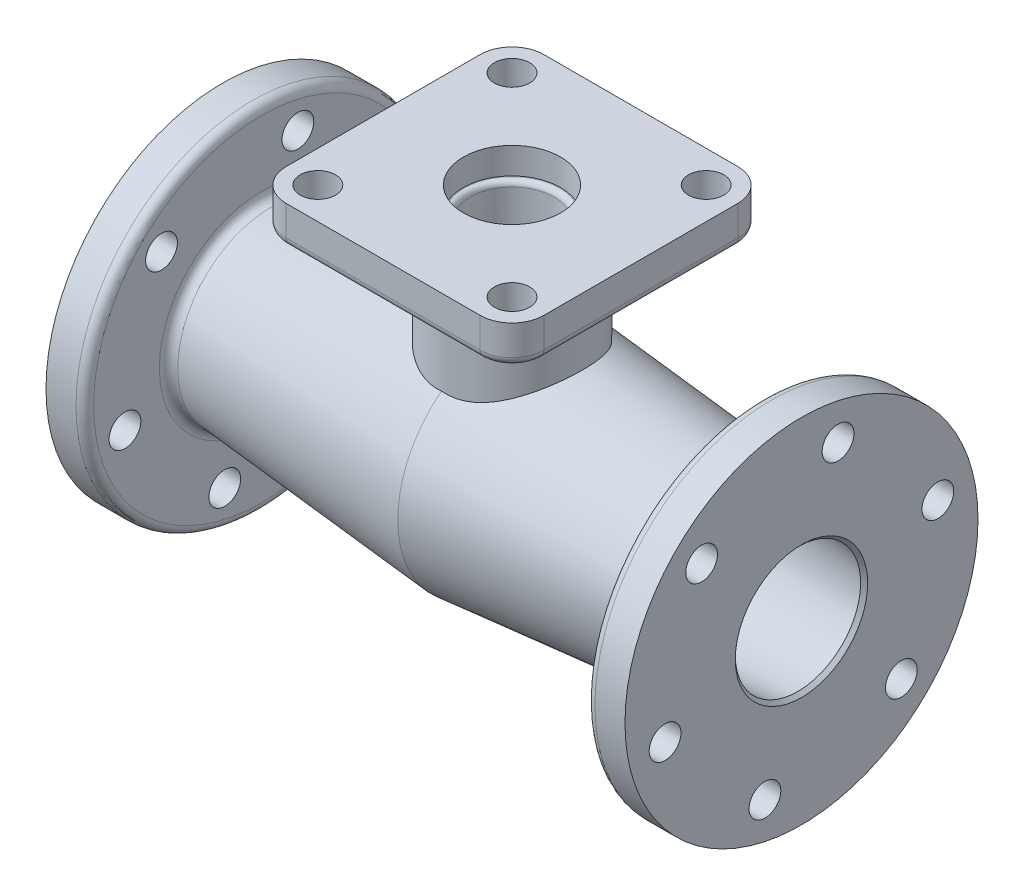
from build123d import *

# Parameters (mm, degrees)
BOSS_EXTRUDE1_START = 50.578696
SKETCH3_R           = 40
BOSS_EXTRUDE1_DEPTH = 59.421304
SKETCH5_R           = 10
BOSS_EXTRUDE2_DEPTH = 22
SKETCH7_R           = 9
CUT_EXTRUDE3_DEPTH  = 22
CUT_EXTRUDE4_START  = -328
SKETCH7_8_R         = 9
CUT_EXTRUDE4_DEPTH  = 22
FILLET1_R           = 5


with BuildPart() as part:
    # Sketch2 → Revolve1 (revolve)
    with BuildSketch(Plane.XY):
        with BuildLine():
            Line((-164, 100), (-147, 100))
            ThreePointArc((-147, 100), (-143.464466094, 98.535533906), (-142, 95))
            Line((-142, 95), (-142, 57.763613339))
            ThreePointArc((-142, 57.763613339), (-140.377951038, 54.077226655), (-136.564221286, 52.782639849))
            Line((-136.564221286, 52.782639849), (0, 64.730461054))
            Line((0, 64.730461054), (136.564221286, 52.782639849))
            ThreePointArc((136.564221286, 52.782639849), (140.377951038, 54.077226655), (142, 57.763613339))
            Line((142, 57.763613339), (142, 95))
            ThreePointArc((142, 95), (143.464466094, 98.535533906), (147, 100))
            Line((147, 100), (164, 100))
            Line((164, 100), (164, 37.5))
            Line((164, 37.5), (162, 35.5))
            Line((162, 35.5), (0, 49.673163491))
            Line((0, 49.673163491), (-162, 35.5))
            Line((-162, 35.5), (-164, 37.5))
            Line((-164, 37.5), (-164, 100))
        make_face()
    revolve(axis=Axis((-164, 0, 0), (1, 0, 0)))

    # Sketch3 → Boss-Extrude1 (add)
    with BuildSketch(Plane(origin=(0, 0, 0), x_dir=(1, 0, 0), z_dir=(0, 1, 0)).offset(BOSS_EXTRUDE1_START)):
        Circle(SKETCH3_R)
    extrude(amount=BOSS_EXTRUDE1_DEPTH)

    # Sketch5 → Boss-Extrude2 (add)
    with BuildSketch(Plane(origin=(0, 110, 0), x_dir=(1, 0, 0), z_dir=(0, 1, 0))):
        with BuildLine():
            Line((55, 73), (-55, 73))
            ThreePointArc((-55, 73), (-67.727922061, 67.727922061), (-73, 55))
            Line((-73, 55), (-73, -55))
            ThreePointArc((-73, -55), (-67.727922061, -67.727922061), (-55, -73))
            Line((-55, -73), (55, -73))
            ThreePointArc((55, -73), (67.727922061, -67.727922061), (73, -55))
            Line((73, -55), (73, 55))
            ThreePointArc((73, 55), (67.727922061, 67.727922061), (55, 73))
        make_face()
        with Locations((-55, 55)):
            Circle(SKETCH5_R, mode=Mode.SUBTRACT)
        with Locations((55, 55)):
            Circle(SKETCH5_R, mode=Mode.SUBTRACT)
        with Locations((55, -55)):
            Circle(SKETCH5_R, mode=Mode.SUBTRACT)
        with Locations((-55, -55)):
            Circle(SKETCH5_R, mode=Mode.SUBTRACT)
    extrude(amount=BOSS_EXTRUDE2_DEPTH)

    # Sketch6 → Cut-Revolve2 (revolve, cut)
    with BuildSketch(Plane.XY):
        with BuildLine():
            Line((0, 132), (-27.5, 132))
            Line((-27.5, 132), (-27.5, 117))
            Line((-27.5, 117), (-26.948091789, 117))
            ThreePointArc((-26.948091789, 117), (-24.845363996, 116.139751347), (-23.948548704, 114.052357219))
            Line((-23.948548704, 114.052357219), (-21.836984951, -6.919049142))
            Line((-21.836984951, -6.919049142), (0, -6.919049142))
            Line((0, -6.919049142), (0, 132))
        make_face()
    revolve(axis=Axis((0, 132, 0), (0, -1, 0)), mode=Mode.SUBTRACT)

    # Sketch7 → Cut-Extrude3 (cut)
    with BuildSketch(Plane(origin=(164, 0, 0), x_dir=(0, 0, -1), z_dir=(1, 0, 0))):
        with Locations((-77.274066103, -20.705523608)):
            Circle(SKETCH7_R)
        with Locations((-56.568542495, 56.568542495)):
            Circle(SKETCH7_R)
        with Locations((20.705523608, 77.274066103)):
            Circle(SKETCH7_R)
        with Locations((77.274066103, 20.705523608)):
            Circle(SKETCH7_R)
        with Locations((56.568542495, -56.568542495)):
            Circle(SKETCH7_R)
        with Locations((-20.705523608, -77.274066103)):
            Circle(SKETCH7_R)
    extrude(amount=-CUT_EXTRUDE3_DEPTH, mode=Mode.SUBTRACT)

    # Sketch7_8 → Cut-Extrude4 (cut)
    with BuildSketch(Plane(origin=(164, 0, 0), x_dir=(0, 0, -1), z_dir=(1, 0, 0)).offset(CUT_EXTRUDE4_START)):
        with Locations((-77.274066103, -20.705523608)):
            Circle(SKETCH7_8_R)
        with Locations((-56.568542495, 56.568542495)):
            Circle(SKETCH7_8_R)
        with Locations((20.705523608, 77.274066103)):
            Circle(SKETCH7_8_R)
        with Locations((77.274066103, 20.705523608)):
            Circle(SKETCH7_8_R)
        with Locations((56.568542495, -56.568542495)):
            Circle(SKETCH7_8_R)
        with Locations((-20.705523608, -77.274066103)):
            Circle(SKETCH7_8_R)
    extrude(amount=CUT_EXTRUDE4_DEPTH, mode=Mode.SUBTRACT)

    # Fillet1
    fillet1_edges = [part.edges().sort_by_distance(p)[0] for p in [
        (67.727922061, 110, -67.727922061),
        (0, 110, -73),
        (-67.727922061, 110, -67.727922061),
        (-73, 110, 0),
        (-67.727922061, 110, 67.727922061),
        (0, 110, 73),
        (67.727922061, 110, 67.727922061),
        (73, 110, 0),
    ]]
    fillet(fillet1_edges, radius=FILLET1_R)


solid = part.part
